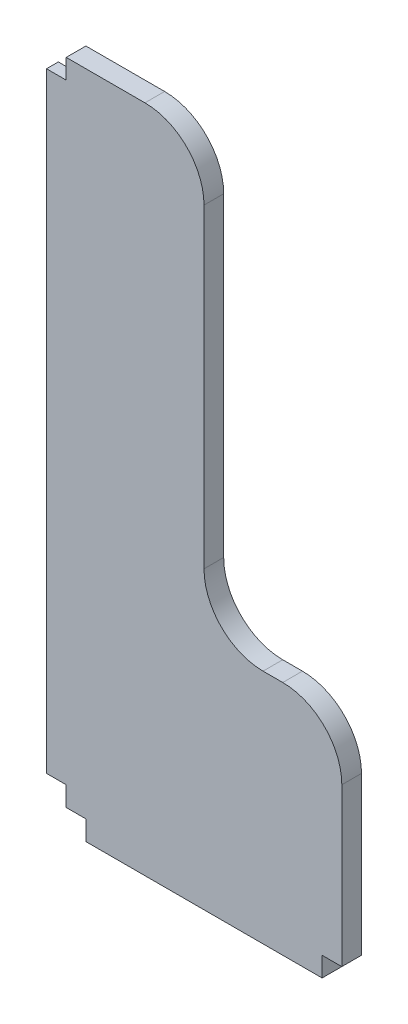
from build123d import *

# Parameters (mm, degrees)
SALIENTE_EXTRUIR3_DEPTH = 6.35
CROQUIS5_W              = 2.54
CROQUIS5_H              = 196.85
CORTAR_EXTRUIR1_DEPTH   = 6.35


with BuildPart() as part:
    # Croquis2 → Saliente-Extruir3 (new body)
    with BuildSketch(Plane.XY):
        with BuildLine():
            Line((0, 0), (6.35, 0))
            Line((6.35, 0), (6.35, -6.35))
            Line((6.35, -6.35), (82.55, -6.35))
            Line((82.55, -6.35), (82.55, 0))
            Line((82.55, 0), (88.9, 0))
            Line((88.9, 0), (88.9, 50.8))
            ThreePointArc((88.9, 50.8), (83.320384182, 64.270384182), (69.85, 69.85))
            Line((69.85, 69.85), (63.5, 69.85))
            ThreePointArc((63.5, 69.85), (50.029615818, 75.429615818), (44.45, 88.9))
            Line((44.45, 88.9), (44.45, 190.5))
            ThreePointArc((44.45, 190.5), (38.870384182, 203.970384182), (25.4, 209.55))
            Line((25.4, 209.55), (0, 209.55))
            Line((0, 209.55), (0, 203.2))
            Line((0, 203.2), (-6.35, 203.2))
            Line((-6.35, 203.2), (-6.35, 6.35))
            Line((-6.35, 6.35), (0, 6.35))
            Line((0, 6.35), (0, 0))
        make_face()
    extrude(amount=SALIENTE_EXTRUIR3_DEPTH)

    # Croquis5 → Cortar-Extruir1 (cut)
    with BuildSketch(Plane.ZY.offset(6.35)):
        with Locations((1.27, 104.775)):
            Rectangle(CROQUIS5_W, CROQUIS5_H)
    extrude(amount=-CORTAR_EXTRUIR1_DEPTH, mode=Mode.SUBTRACT)


solid = part.part
